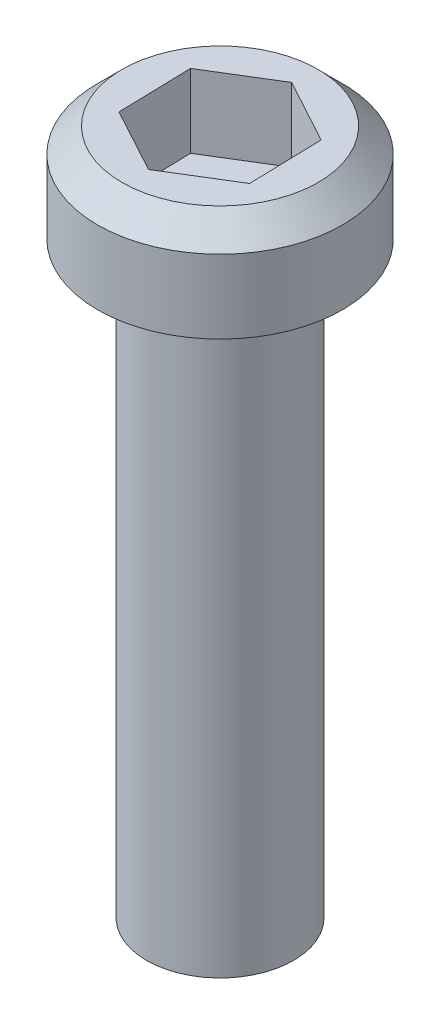
from build123d import *

# Parameters (mm, degrees)
SKETCH1_R           = 1.5
BOSS_EXTRUDE1_DEPTH = 12
SKETCH2_R           = 2.5
BOSS_EXTRUDE2_DEPTH = 2
CHAMFER1_SIZE       = 0.5
CUT_EXTRUDE1_DEPTH  = 1.5


with BuildPart() as part:
    # Sketch1 → Boss-Extrude1 (new body)
    with BuildSketch(Plane(origin=(0, 0, 0), x_dir=(1, 0, 0), z_dir=(0, 1, 0))):
        with Locations((-74.537838868, 155.62707166)):
            Circle(SKETCH1_R)
    extrude(amount=-BOSS_EXTRUDE1_DEPTH)

    # Sketch2 → Boss-Extrude2 (add)
    with BuildSketch(Plane(origin=(0, 0, 0), x_dir=(1, 0, 0), z_dir=(0, 1, 0))):
        with Locations((-74.537838868, 155.62707166)):
            Circle(SKETCH2_R)
    extrude(amount=BOSS_EXTRUDE2_DEPTH)

    # Chamfer1
    chamfer1_edges = [part.edges().sort_by_distance(p)[0] for p in [
        (-77.037838868, 2, -155.62707166),
    ]]
    chamfer(chamfer1_edges, length=CHAMFER1_SIZE)

    # Sketch3 → Cut-Extrude1 (cut)
    with BuildSketch(Plane(origin=(0, 2, 0), x_dir=(1, 0, 0), z_dir=(0, 1, 0))):
        Polygon((-73.219689644, 154.911192742), (-73.258794928, 156.410682915), (-74.576944151, 157.126561832), (-75.855988091, 156.342950577), (-75.816882808, 154.843460404), (-74.498733584, 154.127581487), align=None)
    extrude(amount=-CUT_EXTRUDE1_DEPTH, mode=Mode.SUBTRACT)


solid = part.part
